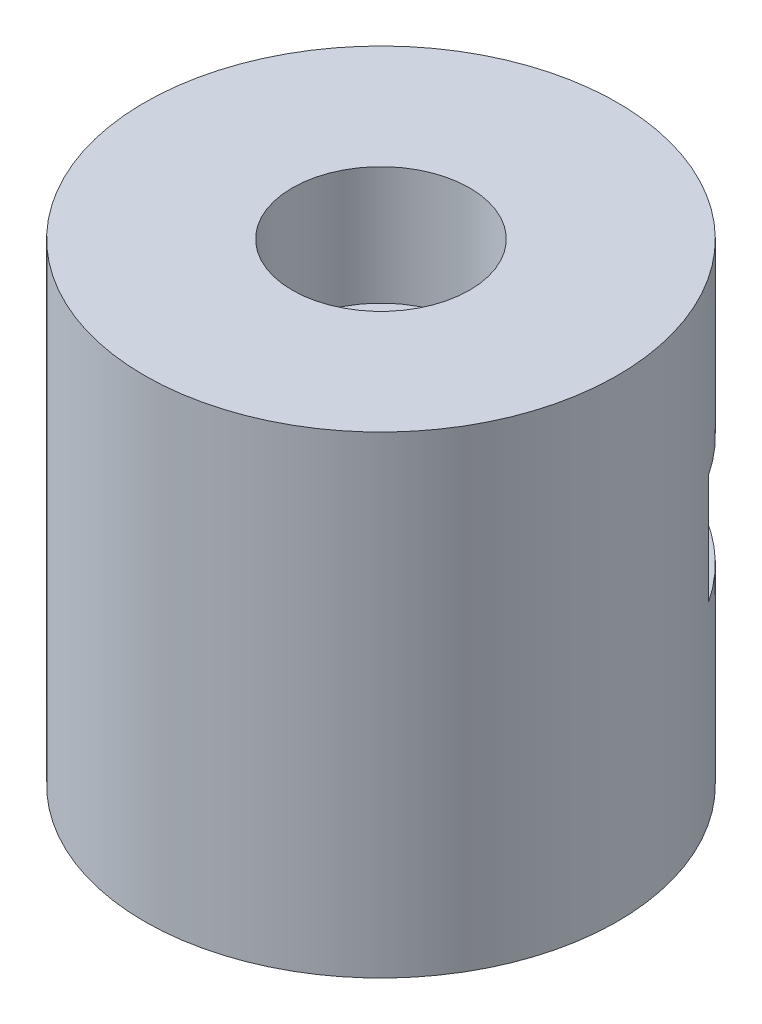
from build123d import *

# Parameters (mm, degrees)
SKETCH1_R           = 20
BOSS_EXTRUDE1_DEPTH = 40
SKETCH2_R           = 7.5
CUT_EXTRUDE1_DEPTH  = 10
SKETCH3_W           = 33.40458463
SKETCH3_H           = 9.314739944
CUT_EXTRUDE2_DEPTH  = 10


with BuildPart() as part:
    # Sketch1 → Boss-Extrude1 (new body)
    with BuildSketch(Plane(origin=(0, 0, 0), x_dir=(1, 0, 0), z_dir=(0, 1, 0))):
        Circle(SKETCH1_R)
    extrude(amount=BOSS_EXTRUDE1_DEPTH)

    # Sketch2 → Cut-Extrude1 (cut)
    with BuildSketch(Plane(origin=(0, 40, 0), x_dir=(1, 0, 0), z_dir=(0, 1, 0))):
        Circle(SKETCH2_R)
    extrude(amount=-CUT_EXTRUDE1_DEPTH, mode=Mode.SUBTRACT)

    # Sketch3 → Cut-Extrude2 (cut)
    with BuildSketch(Plane.XY.offset(-20)):
        with Locations((0, 20.883294305)):
            Rectangle(SKETCH3_W, SKETCH3_H)
    extrude(amount=CUT_EXTRUDE2_DEPTH, mode=Mode.SUBTRACT)


solid = part.part
